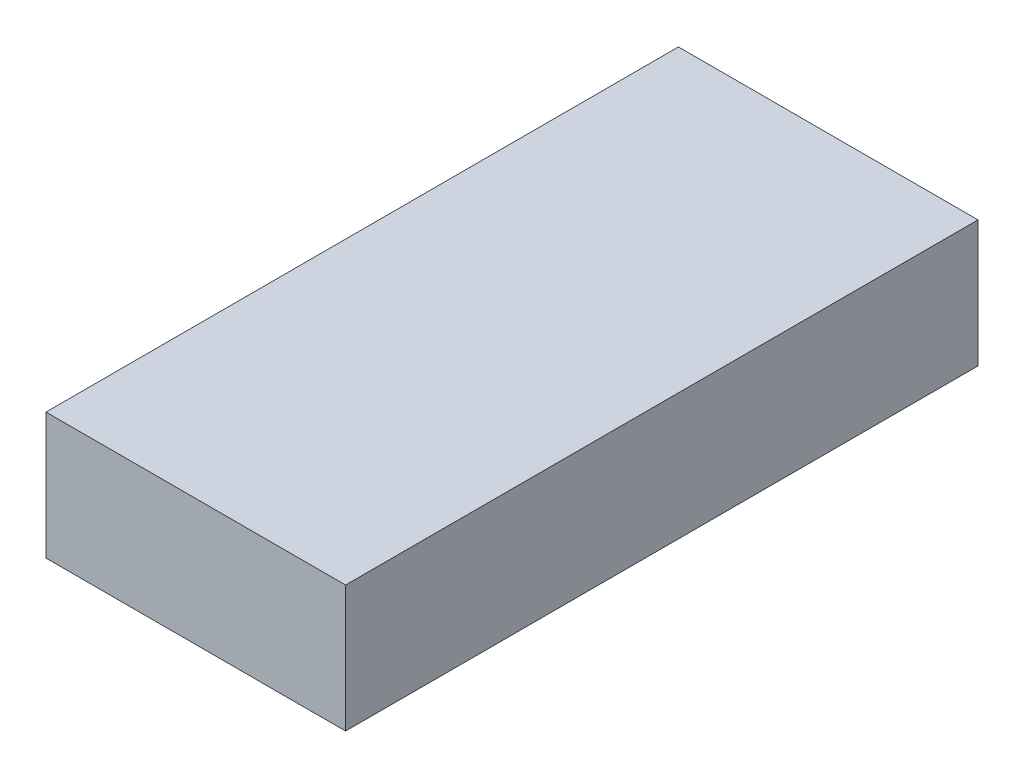
from build123d import *

# Parameters (mm, degrees)
SKETCH1_W           = 900
SKETCH1_H           = 1900
BOSS_EXTRUDE1_DEPTH = 380


with BuildPart() as part:
    # Sketch1 → Boss-Extrude1 (new body)
    with BuildSketch(Plane(origin=(0, 0, 0), x_dir=(1, 0, 0), z_dir=(0, 1, 0))):
        with Locations((-249.622641509, -466.037735849)):
            Rectangle(SKETCH1_W, SKETCH1_H)
    extrude(amount=BOSS_EXTRUDE1_DEPTH)


solid = part.part
